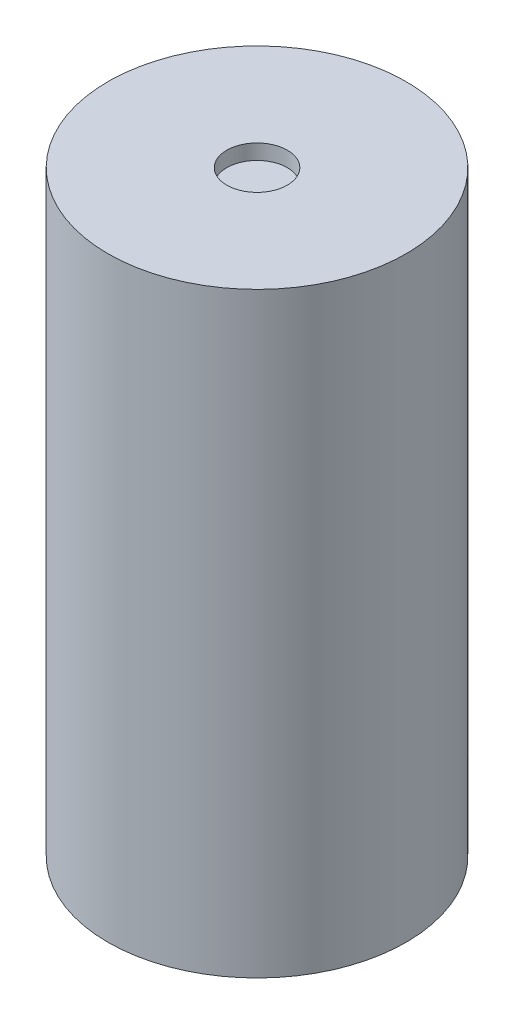
from build123d import *

# Parameters (mm, degrees)
SKETCH1_R           = 250
BOSS_EXTRUDE1_DEPTH = 1000
SKETCH2_R           = 50.8
CUT_EXTRUDE1_DEPTH  = 25.4


with BuildPart() as part:
    # Sketch1 → Boss-Extrude1 (new body)
    with BuildSketch(Plane(origin=(0, 0, 0), x_dir=(1, 0, 0), z_dir=(0, 1, 0))):
        Circle(SKETCH1_R)
    extrude(amount=BOSS_EXTRUDE1_DEPTH)

    # Sketch2 → Cut-Extrude1 (cut)
    with BuildSketch(Plane(origin=(0, 1000, 0), x_dir=(1, 0, 0), z_dir=(0, 1, 0))):
        Circle(SKETCH2_R)
    extrude(amount=-CUT_EXTRUDE1_DEPTH, mode=Mode.SUBTRACT)


solid = part.part
